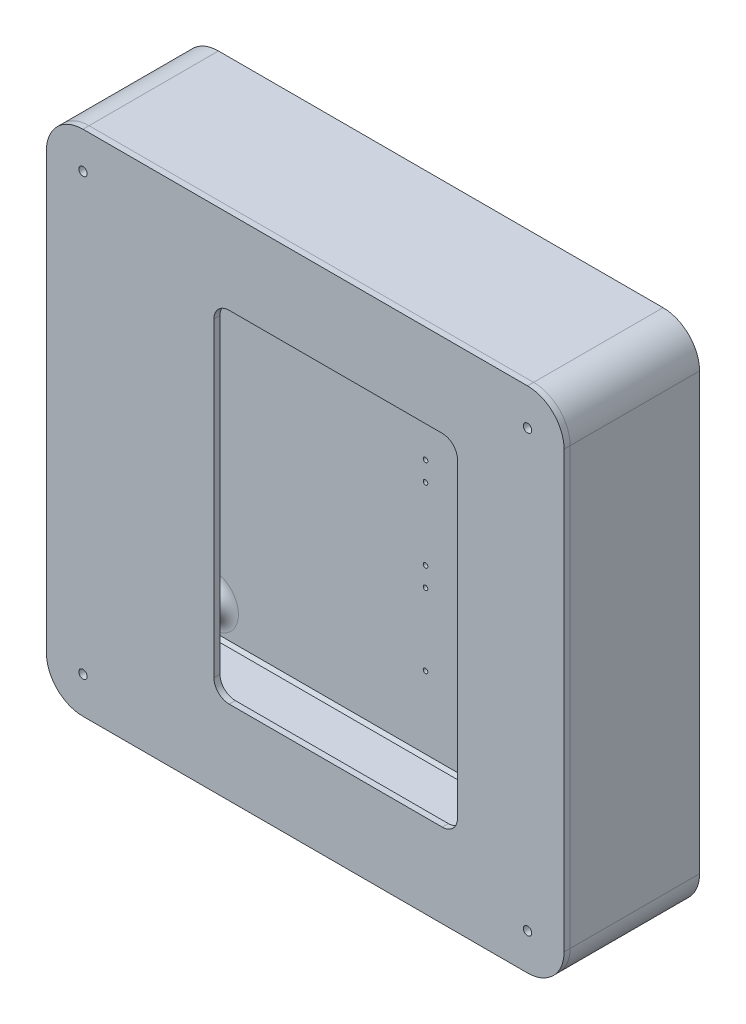
from build123d import *

# Parameters (mm, degrees)
SKETCH1_W           = 334
SKETCH1_H           = 340
SKETCH1_R           = 1.5
SKETCH1_R_2         = 2.1
BOSS_EXTRUDE1_DEPTH = 4
SKETCH1_3_W         = 334
SKETCH1_3_H         = 340
SKETCH1_3_W_2       = 326
SKETCH1_3_H_2       = 332
BOSS_EXTRUDE2_DEPTH = 85
FILLET1_R           = 20
FILLET2_R           = 24
SKETCH1_4_R         = 7.1
SKETCH1_4_R_2       = 2.1
BOSS_EXTRUDE3_DEPTH = 85
CUT_EXTRUDE1_REACH  = 390.219
CUT_EXTRUDE2_REACH  = 388.984
SKETCH4_W           = 35.4
SKETCH4_H           = 61
SKETCH4_W_2         = 25.4
SKETCH4_H_2         = 51
BOSS_EXTRUDE4_DEPTH = 8
CHAMFER1_SIZE       = 2
FILLET3_R           = 10
SKETCH5_W           = 25.4
SKETCH5_H           = 51
CUT_EXTRUDE3_DEPTH  = 2
SKETCH6_R           = 2.75
BOSS_EXTRUDE5_DEPTH = 4
SKETCH7_W           = 160
SKETCH7_H           = 224
CUT_EXTRUDE4_DEPTH  = 4
BOSS_EXTRUDE6_DEPTH = 5
FILLET4_R           = 10


with BuildPart() as part:
    # Sketch1 → Boss-Extrude1 (new body)
    with BuildSketch(Plane(origin=(0, 0, 0), x_dir=(0, 1, 0), z_dir=(0, 0, 1))):
        with Locations((0, -6)):
            Rectangle(SKETCH1_W, SKETCH1_H)
        with Locations(Location((-113.625, 0, 0), (0, 0, 270))):
            Circle(SKETCH1_R, mode=Mode.SUBTRACT)
        with Locations(Location((-66.375, 0, 0), (0, 0, 270))):
            Circle(SKETCH1_R, mode=Mode.SUBTRACT)
        with Locations(Location((-53.625, 0, 0), (0, 0, 270))):
            Circle(SKETCH1_R, mode=Mode.SUBTRACT)
        with Locations(Location((-6.375, 0, 0), (0, 0, 270))):
            Circle(SKETCH1_R, mode=Mode.SUBTRACT)
        with Locations(Location((6.375, 0, 0), (0, 0, 270))):
            Circle(SKETCH1_R, mode=Mode.SUBTRACT)
        with Locations(Location((53.625, 0, 0), (0, 0, 270))):
            Circle(SKETCH1_R, mode=Mode.SUBTRACT)
        with Locations(Location((66.375, 0, 0), (0, 0, 270))):
            Circle(SKETCH1_R, mode=Mode.SUBTRACT)
        with Locations(Location((113.625, 0, 0), (0, 0, 270))):
            Circle(SKETCH1_R, mode=Mode.SUBTRACT)
        with Locations(Location((143, -152, 0), (0, 0, 270))):
            Circle(SKETCH1_R_2, mode=Mode.SUBTRACT)
        with Locations(Location((-143, -152, 0), (0, 0, 270))):
            Circle(SKETCH1_R_2, mode=Mode.SUBTRACT)
        with Locations(Location((-143, 140, 0), (0, 0, 270))):
            Circle(SKETCH1_R_2, mode=Mode.SUBTRACT)
        with Locations(Location((143, 140, 0), (0, 0, 270))):
            Circle(SKETCH1_R_2, mode=Mode.SUBTRACT)
    extrude(amount=BOSS_EXTRUDE1_DEPTH)

    # Sketch1_3 → Boss-Extrude2 (add)
    with BuildSketch(Plane(origin=(0, 0, 0), x_dir=(0, 1, 0), z_dir=(0, 0, 1))):
        with Locations((0, -6)):
            Rectangle(SKETCH1_3_W, SKETCH1_3_H)
        with Locations((0, -6)):
            Rectangle(SKETCH1_3_W_2, SKETCH1_3_H_2, mode=Mode.SUBTRACT)
    extrude(amount=BOSS_EXTRUDE2_DEPTH)

    # Fillet1
    fillet1_edges = [part.edges().sort_by_distance(p)[0] for p in [
        (-160, -163, 44.5),
        (-160, 163, 44.5),
        (172, 163, 44.5),
        (172, -163, 44.5),
    ]]
    fillet(fillet1_edges, radius=FILLET1_R)

    # Fillet2
    fillet2_edges = [part.edges().sort_by_distance(p)[0] for p in [
        (-164, 167, 42.5),
        (176, 167, 42.5),
        (176, -167, 42.5),
        (-164, -167, 42.5),
    ]]
    fillet(fillet2_edges, radius=FILLET2_R)

    # Sketch1_4 → Boss-Extrude3 (add)
    with BuildSketch(Plane(origin=(0, 0, 0), x_dir=(0, 1, 0), z_dir=(0, 0, 1))):
        with Locations(Location((143, -152, 0), (0, 0, 270))):
            Circle(SKETCH1_4_R)
        with Locations(Location((143, -152, 0), (0, 0, 270))):
            Circle(SKETCH1_4_R_2, mode=Mode.SUBTRACT)
        with Locations(Location((-143, -152, 0), (0, 0, 270))):
            Circle(SKETCH1_4_R)
        with Locations(Location((-143, -152, 0), (0, 0, 270))):
            Circle(SKETCH1_4_R_2, mode=Mode.SUBTRACT)
        with Locations(Location((-143, 140, 0), (0, 0, 270))):
            Circle(SKETCH1_4_R)
        with Locations(Location((-143, 140, 0), (0, 0, 270))):
            Circle(SKETCH1_4_R_2, mode=Mode.SUBTRACT)
        with Locations(Location((143, 140, 0), (0, 0, 270))):
            Circle(SKETCH1_4_R)
        with Locations(Location((143, 140, 0), (0, 0, 270))):
            Circle(SKETCH1_4_R_2, mode=Mode.SUBTRACT)
    extrude(amount=BOSS_EXTRUDE3_DEPTH)

    # Sketch2 → Cut-Extrude1 (cut, up to next)
    with BuildSketch(Plane(origin=(-164, 0, 0), x_dir=(0, -1, 0), z_dir=(-1, 0, 0)), mode=Mode.PRIVATE) as cut_extrude1_sk1:
        with BuildLine():
            Line((-92.898275349, 12.35), (-87.101724651, 12.35))
            ThreePointArc((-87.101724651, 12.35), (-90, 24.35), (-92.898275349, 12.35))
        make_face()
    cut_extrude1_tool1 = extrude(cut_extrude1_sk1.sketch, amount=-CUT_EXTRUDE1_REACH, mode=Mode.PRIVATE) & part.part
    # Sketch2 → Cut-Extrude1 (cut, up to next)
    with BuildSketch(Plane(origin=(-164, 0, 0), x_dir=(0, -1, 0), z_dir=(-1, 0, 0)), mode=Mode.PRIVATE) as cut_extrude1_sk2:
        with BuildLine():
            Line((-32.898275349, 12.35), (-27.101724651, 12.35))
            ThreePointArc((-27.101724651, 12.35), (-30, 24.35), (-32.898275349, 12.35))
        make_face()
    cut_extrude1_tool2 = extrude(cut_extrude1_sk2.sketch, amount=-CUT_EXTRUDE1_REACH, mode=Mode.PRIVATE) & part.part
    # Sketch2 → Cut-Extrude1 (cut, up to next)
    with BuildSketch(Plane(origin=(-164, 0, 0), x_dir=(0, -1, 0), z_dir=(-1, 0, 0)), mode=Mode.PRIVATE) as cut_extrude1_sk3:
        with BuildLine():
            Line((27.101724651, 12.35), (32.898275349, 12.35))
            ThreePointArc((32.898275349, 12.35), (30, 24.35), (27.101724651, 12.35))
        make_face()
    cut_extrude1_tool3 = extrude(cut_extrude1_sk3.sketch, amount=-CUT_EXTRUDE1_REACH, mode=Mode.PRIVATE) & part.part
    # Sketch2 → Cut-Extrude1 (cut, up to next)
    with BuildSketch(Plane(origin=(-164, 0, 0), x_dir=(0, -1, 0), z_dir=(-1, 0, 0)), mode=Mode.PRIVATE) as cut_extrude1_sk4:
        with BuildLine():
            Line((87.101724651, 12.35), (92.898275349, 12.35))
            ThreePointArc((92.898275349, 12.35), (90, 24.35), (87.101724651, 12.35))
        make_face()
    cut_extrude1_tool4 = extrude(cut_extrude1_sk4.sketch, amount=-CUT_EXTRUDE1_REACH, mode=Mode.PRIVATE) & part.part
    add(cut_extrude1_tool1.solids().sort_by_distance((-164, 90, 18.130953))[0], mode=Mode.SUBTRACT)
    add(cut_extrude1_tool2.solids().sort_by_distance((-164, 30, 18.130953))[0], mode=Mode.SUBTRACT)
    add(cut_extrude1_tool3.solids().sort_by_distance((-164, -30, 18.130953))[0], mode=Mode.SUBTRACT)
    add(cut_extrude1_tool4.solids().sort_by_distance((-164, -90, 18.130953))[0], mode=Mode.SUBTRACT)

    # Sketch3 → Cut-Extrude2 (cut, up to next)
    with BuildSketch(Plane.XZ.offset(167), mode=Mode.PRIVATE) as cut_extrude2_sk1:
        with BuildLine():
            Line((139.101724651, 12.35), (144.898275349, 12.35))
            ThreePointArc((144.898275349, 12.35), (142, 24.35), (139.101724651, 12.35))
        make_face()
    cut_extrude2_tool1 = extrude(cut_extrude2_sk1.sketch, amount=-CUT_EXTRUDE2_REACH, mode=Mode.PRIVATE) & part.part
    add(cut_extrude2_tool1.solids().sort_by_distance((142, -167, 18.130953))[0], mode=Mode.SUBTRACT)

    # Sketch4 → Boss-Extrude4 (add)
    with BuildSketch(Plane.XY.offset(4)):
        with Locations((150, 95.5)):
            Rectangle(SKETCH4_W, SKETCH4_H)
        with Locations((150, 95.5)):
            Rectangle(SKETCH4_W_2, SKETCH4_H_2, mode=Mode.SUBTRACT)
        with Locations((150, -95.5)):
            Rectangle(SKETCH4_W, SKETCH4_H)
        with Locations((150, -95.5)):
            Rectangle(SKETCH4_W_2, SKETCH4_H_2, mode=Mode.SUBTRACT)
    extrude(amount=BOSS_EXTRUDE4_DEPTH)

    # Chamfer1
    chamfer1_edges = [part.edges().sort_by_distance(p)[0] for p in [
        (-160, 0, 4),
        (6, 163, 4),
        (6, -163, 4),
        (172, 0, 4),
        (-154.142135624, 157.142135624, 4),
        (166.142135624, 157.142135624, 4),
        (166.142135624, -157.142135624, 4),
        (-154.142135624, -157.142135624, 4),
    ]]
    chamfer(chamfer1_edges, length=CHAMFER1_SIZE)

    # Fillet3
    fillet3_edges = [part.edges().sort_by_distance(p)[0] for p in [
        (-147.1, 143, 4),
        (-147.1, -143, 4),
        (144.9, -143, 4),
        (144.9, 143, 4),
    ]]
    fillet(fillet3_edges, radius=FILLET3_R)

    # Sketch5 → Cut-Extrude3 (cut)
    with BuildSketch(Plane.XY.offset(4)):
        with Locations((150, -95.5)):
            Rectangle(SKETCH5_W, SKETCH5_H)
        with Locations((150, 95.5)):
            Rectangle(SKETCH5_W, SKETCH5_H)
    extrude(amount=-CUT_EXTRUDE3_DEPTH, mode=Mode.SUBTRACT)


with BuildPart() as body_2:
    # Sketch6 → Boss-Extrude5 (new body)
    with BuildSketch(Plane.XY.offset(85)):
        with BuildLine():
            ThreePointArc((-140, 167), (-156.970562748, 159.970562748), (-164, 143))
            Line((-164, 143), (-164, -143))
            ThreePointArc((-164, -143), (-156.970562748, -159.970562748), (-140, -167))
            Line((-140, -167), (152, -167))
            ThreePointArc((152, -167), (168.970562748, -159.970562748), (176, -143))
            Line((176, -143), (176, 143))
            ThreePointArc((176, 143), (168.970562748, 159.970562748), (152, 167))
            Line((152, 167), (-140, 167))
        make_face()
        with BuildLine():
            ThreePointArc((172, -143), (166.142135624, -157.142135624), (152, -163))
            Line((152, -163), (-140, -163))
            ThreePointArc((-140, -163), (-154.142135624, -157.142135624), (-160, -143))
            Line((-160, -143), (-160, 143))
            ThreePointArc((-160, 143), (-154.142135624, 157.142135624), (-140, 163))
            Line((-140, 163), (152, 163))
            ThreePointArc((152, 163), (166.142135624, 157.142135624), (172, 143))
            Line((172, 143), (172, -143))
        make_face(mode=Mode.SUBTRACT)
        with BuildLine():
            Line((152, -163), (-140, -163))
            ThreePointArc((-140, -163), (-154.142135624, -157.142135624), (-160, -143))
            Line((-160, -143), (-160, 143))
            ThreePointArc((-160, 143), (-154.142135624, 157.142135624), (-140, 163))
            Line((-140, 163), (152, 163))
            ThreePointArc((152, 163), (166.142135624, 157.142135624), (172, 143))
            Line((172, 143), (172, -143))
            ThreePointArc((172, -143), (166.142135624, -157.142135624), (152, -163))
        make_face()
        with BuildLine():
            ThreePointArc((152, -159), (163.313708499, -154.313708499), (168, -143))
            Line((168, -143), (168, 143))
            ThreePointArc((168, 143), (163.313708499, 154.313708499), (152, 159))
            Line((152, 159), (-140, 159))
            ThreePointArc((-140, 159), (-151.313708499, 154.313708499), (-156, 143))
            Line((-156, 143), (-156, -143))
            ThreePointArc((-156, -143), (-151.313708499, -154.313708499), (-140, -159))
            Line((-140, -159), (152, -159))
        make_face(mode=Mode.SUBTRACT)
        with BuildLine():
            Line((-140, -159), (152, -159))
            ThreePointArc((152, -159), (163.313708499, -154.313708499), (168, -143))
            Line((168, -143), (168, 143))
            ThreePointArc((168, 143), (163.313708499, 154.313708499), (152, 159))
            Line((152, 159), (-140, 159))
            ThreePointArc((-140, 159), (-151.313708499, 154.313708499), (-156, 143))
            Line((-156, 143), (-156, -143))
            ThreePointArc((-156, -143), (-151.313708499, -154.313708499), (-140, -159))
        make_face()
        with Locations((152, 143)):
            Circle(SKETCH6_R, mode=Mode.SUBTRACT)
        with Locations((152, -143)):
            Circle(SKETCH6_R, mode=Mode.SUBTRACT)
        with Locations((-140, -143)):
            Circle(SKETCH6_R, mode=Mode.SUBTRACT)
        with Locations((-140, 143)):
            Circle(SKETCH6_R, mode=Mode.SUBTRACT)
    extrude(amount=BOSS_EXTRUDE5_DEPTH)

    # Sketch7 → Cut-Extrude4 (cut)
    with BuildSketch(Plane.XY.offset(89)):
        with Locations((26, 0)):
            Rectangle(SKETCH7_W, SKETCH7_H)
    extrude(amount=-CUT_EXTRUDE4_DEPTH, mode=Mode.SUBTRACT)

    # Sketch6_3 → Boss-Extrude6 (add)
    with BuildSketch(Plane.XY.offset(85)):
        with BuildLine():
            Line((-140, -163), (152, -163))
            ThreePointArc((152, -163), (166.142135624, -157.142135624), (172, -143))
            Line((172, -143), (172, 143))
            ThreePointArc((172, 143), (166.142135624, 157.142135624), (152, 163))
            Line((152, 163), (-140, 163))
            ThreePointArc((-140, 163), (-154.142135624, 157.142135624), (-160, 143))
            Line((-160, 143), (-160, -143))
            ThreePointArc((-160, -143), (-154.142135624, -157.142135624), (-140, -163))
        make_face()
        with BuildLine():
            Line((168, -143), (168, 143))
            ThreePointArc((168, 143), (163.313708499, 154.313708499), (152, 159))
            Line((152, 159), (-140, 159))
            ThreePointArc((-140, 159), (-151.313708499, 154.313708499), (-156, 143))
            Line((-156, 143), (-156, -143))
            ThreePointArc((-156, -143), (-151.313708499, -154.313708499), (-140, -159))
            Line((-140, -159), (152, -159))
            ThreePointArc((152, -159), (163.313708499, -154.313708499), (168, -143))
        make_face(mode=Mode.SUBTRACT)
    extrude(amount=-BOSS_EXTRUDE6_DEPTH)

    # Fillet4
    fillet4_edges = [body_2.edges().sort_by_distance(p)[0] for p in [
        (106, 112, 87),
        (106, -112, 87),
        (-54, -112, 87),
        (-54, 112, 87),
    ]]
    fillet(fillet4_edges, radius=FILLET4_R)


solid = Compound([part.part, body_2.part])
